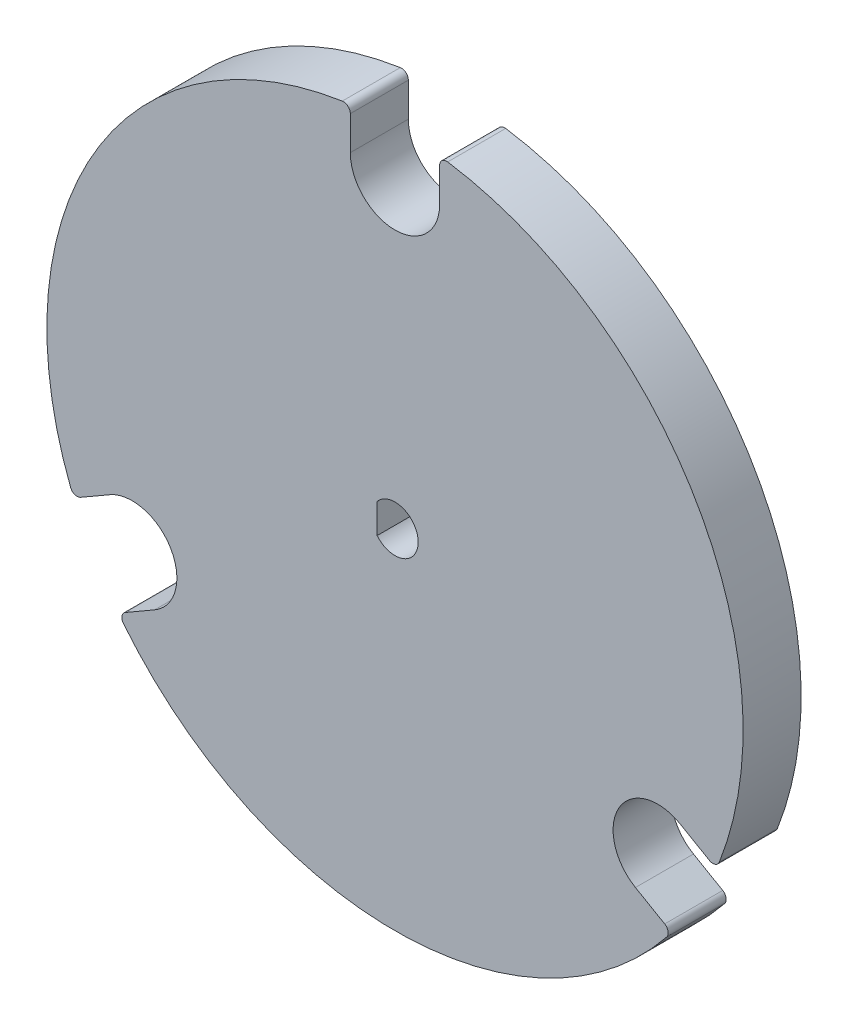
from build123d import *

# Parameters (mm, degrees)
SKETCH1_R           = 38.1
BOSS_EXTRUDE1_DEPTH = 6.35
CUT_EXTRUDE1_DEPTH  = 7.35
FILLET1_R           = 0.762
CUT_EXTRUDE3_DEPTH  = 7.35


with BuildPart() as part:
    # Sketch1 → Boss-Extrude1 (new body)
    with BuildSketch(Plane.XY):
        Circle(SKETCH1_R)
    extrude(amount=BOSS_EXTRUDE1_DEPTH)

    # Sketch2 → Cut-Extrude1 (cut, through all)
    with BuildSketch(Plane.XY.offset(6.35)):
        with BuildLine():
            Line((-4.8895, 33.2105), (-4.8895, 37.784954542))
            ThreePointArc((-4.8895, 37.784954542), (0, 38.1), (4.8895, 37.784954542))
            Line((4.8895, 37.784954542), (4.8895, 33.2105))
            ThreePointArc((4.8895, 33.2105), (0, 28.321), (-4.8895, 33.2105))
        make_face()
        with BuildLine():
            Line((31.205886672, -12.370818788), (35.167480514, -14.658046059))
            ThreePointArc((35.167480514, -14.658046059), (32.995567884, -19.05), (30.277980514, -23.126908483))
            Line((30.277980514, -23.126908483), (26.316386672, -20.839681212))
            ThreePointArc((26.316386672, -20.839681212), (24.526705461, -14.1605), (31.205886672, -12.370818788))
        make_face()
        with BuildLine():
            Line((-26.316386672, -20.839681212), (-30.277980514, -23.126908483))
            ThreePointArc((-30.277980514, -23.126908483), (-32.995567884, -19.05), (-35.167480514, -14.658046059))
            Line((-35.167480514, -14.658046059), (-31.205886672, -12.370818788))
            ThreePointArc((-31.205886672, -12.370818788), (-24.526705461, -14.1605), (-26.316386672, -20.839681212))
        make_face()
    extrude(amount=-CUT_EXTRUDE1_DEPTH, mode=Mode.SUBTRACT)

    # Fillet1
    fillet1_edges = [part.edges().sort_by_distance(p)[0] for p in [
        (-4.8895, 37.784954542, 3.175),
        (4.8895, 37.784954542, 3.175),
        (35.167480514, -14.658046059, 3.175),
        (30.277980514, -23.126908483, 3.175),
        (-30.277980514, -23.126908483, 3.175),
        (-35.167480514, -14.658046059, 3.175),
    ]]
    fillet(fillet1_edges, radius=FILLET1_R)

    # Sketch4 → Cut-Extrude3 (cut, through all)
    with BuildSketch(Plane.XY.offset(6.35)):
        with BuildLine():
            Line((-1.9558, -1.62063147), (-1.9558, 1.62063147))
            ThreePointArc((-1.9558, 1.62063147), (2.54, 0), (-1.9558, -1.62063147))
        make_face()
    extrude(amount=-CUT_EXTRUDE3_DEPTH, mode=Mode.SUBTRACT)


solid = part.part
